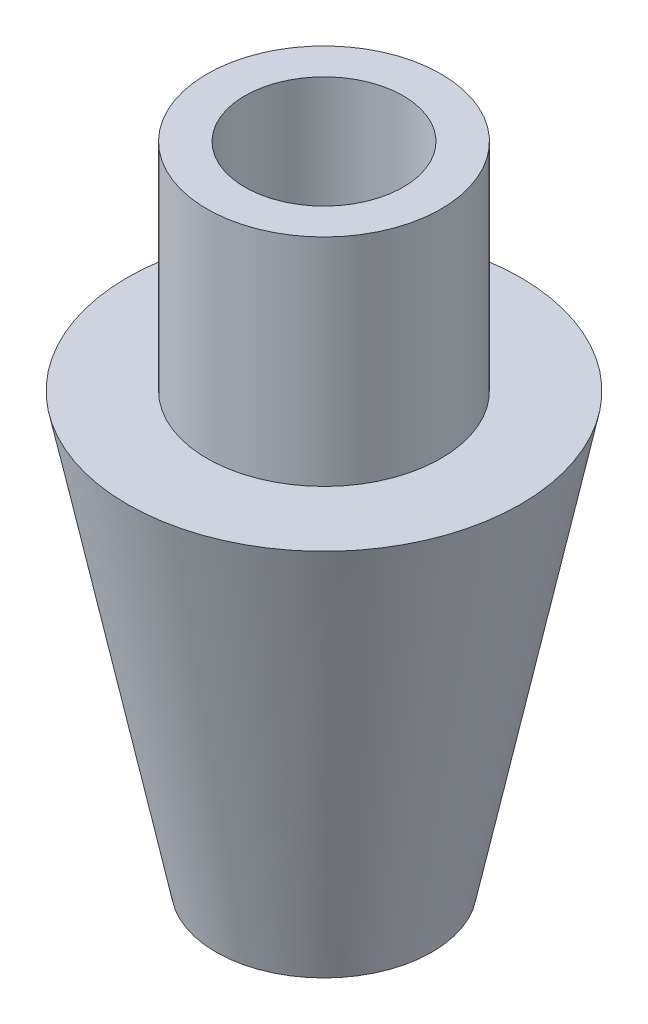
from build123d import *


with BuildPart() as part:
    # Sketch1 → Revolve1 (revolve)
    with BuildSketch(Plane(origin=(0, 0, 0), x_dir=(0, 0, -1), z_dir=(1, 0, 0))):
        Polygon((-13.716, 0), (-19.05, 0), (-34.6583, 76.2), (-20.6375, 76.2), (-20.6375, 114.3), (-13.97, 114.3), (-13.97, 76.2), (-13.716, 76.2), align=None)
    revolve(axis=Axis((0, 0, 0), (0, 1, 0)))


solid = part.part
